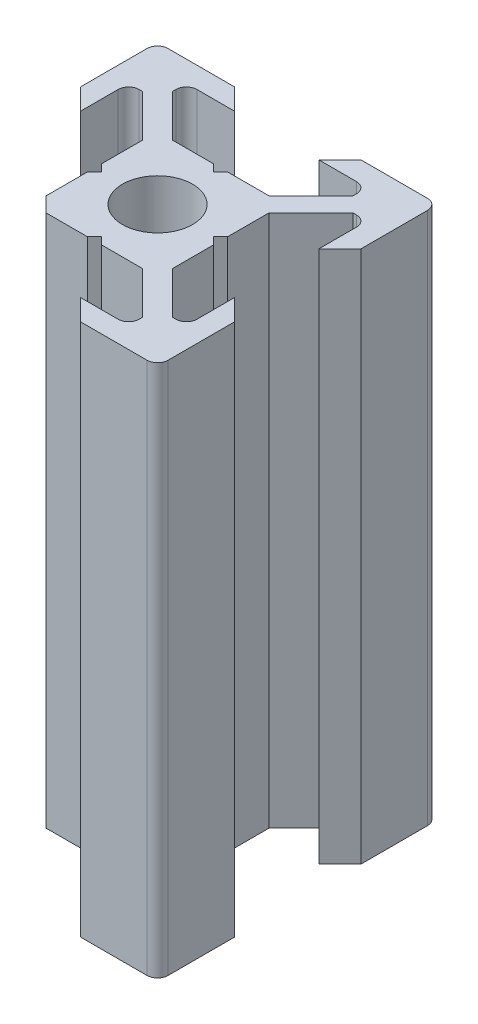
from build123d import *

# Parameters (mm, degrees)
ESQUISSE1_R      = 2.5
EXTRUSION1_DEPTH = 38
CONG_1_R         = 0.75
EXTRUSION2_REACH = 40


with BuildPart() as part:
    # Esquisse1 → Extrusion1 (new body)
    with BuildSketch(Plane(origin=(0, 0, 0), x_dir=(1, 0, 0), z_dir=(0, 1, 0))):
        Polygon((0, 4), (-0.5, 4.5), (-3.439339828, 4.5), (-6.439339828, 7.5), (-6.439339828, 8.5), (-3, 8.5), (-4.5, 10), (-10, 10), (-10, 4.5), (-8.5, 3), (-8.5, 6.439339828), (-7.5, 6.439339828), (-4.5, 3.439339828), (-4.5, 0.5), (-4, 0), (-4.5, -0.5), (-4.5, -3.439339828), (-7.5, -6.439339828), (-8.5, -6.439339828), (-8.5, -3), (-10, -4.5), (-10, -10), (-4.5, -10), (-3, -8.5), (-6.439339828, -8.5), (-6.439339828, -7.5), (-3.439339828, -4.5), (-0.5, -4.5), (0, -4), (0.5, -4.5), (3.439339828, -4.5), (6.439339828, -7.5), (6.439339828, -8.5), (3, -8.5), (4.5, -10), (10, -10), (10, -4.5), (8.5, -3), (8.5, -6.439339828), (7.5, -6.439339828), (4.5, -3.439339828), (4.5, -0.5), (4, 0), (4.5, 0.5), (4.5, 3.439339828), (7.5, 6.439339828), (8.5, 6.439339828), (8.5, 3), (10, 4.5), (10, 10), (4.5, 10), (3, 8.5), (6.439339828, 8.5), (6.439339828, 7.5), (3.439339828, 4.5), (0.5, 4.5), align=None)
        Circle(ESQUISSE1_R, mode=Mode.SUBTRACT)
    extrude(amount=EXTRUSION1_DEPTH)

    # Congé1
    cong_1_edges = [part.edges().sort_by_distance(p)[0] for p in [
        (6.439339828, 19, -8.5),
        (10, 19, -10),
        (8.5, 19, -6.439339828),
        (8.5, 19, 6.439339828),
        (10, 19, 10),
        (6.439339828, 19, 8.5),
        (-6.439339828, 19, 8.5),
        (-10, 19, 10),
        (-8.5, 19, 6.439339828),
        (-8.5, 19, -6.439339828),
        (-10, 19, -10),
        (-6.439339828, 19, -8.5),
    ]]
    fillet(cong_1_edges, radius=CONG_1_R)

    # Esquisse2 → Extrusion2 (cut, up to next)
    with BuildSketch(Plane(origin=(0, 38, 0), x_dir=(1, 0, 0), z_dir=(0, 1, 0)), mode=Mode.PRIVATE) as extrusion2_sk1:
        Polygon((-3.439339828, -4.5), (-4.5, -3.439339828), (-8.5, -3), (-10, -4.5), (-10, -10), (-4.5, -10), (-3, -8.5), align=None)
    extrusion2_tool1 = extrude(extrusion2_sk1.sketch, amount=-EXTRUSION2_REACH, mode=Mode.PRIVATE) & part.part
    add(extrusion2_tool1.solids().sort_by_distance((-6.693883, 38, 6.693883))[0], mode=Mode.SUBTRACT)


solid = part.part
